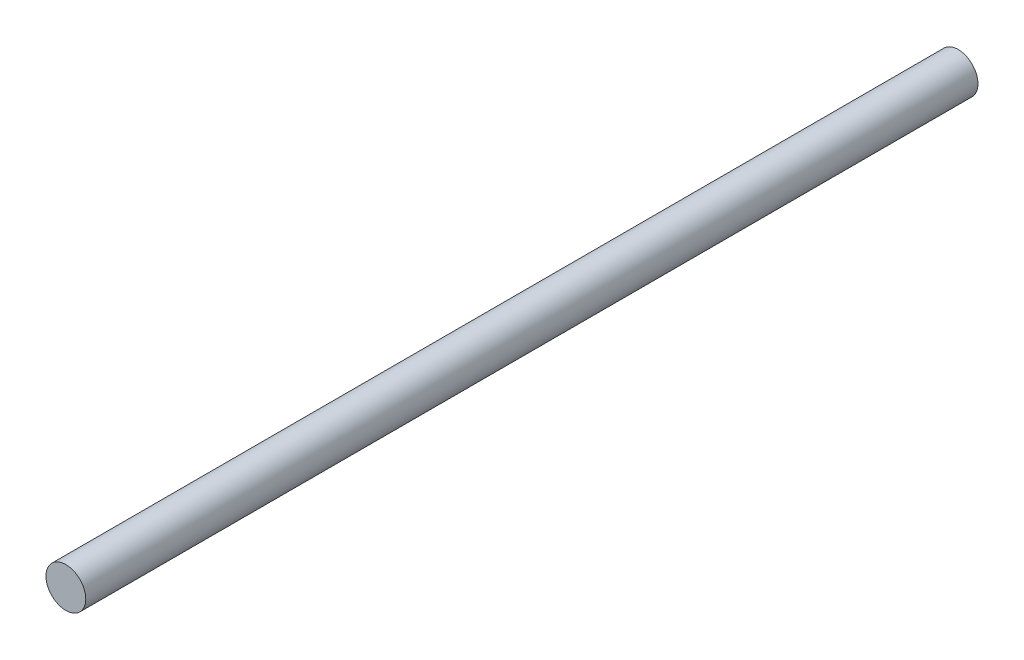
from build123d import *

# Parameters (mm, degrees)
SKETCH1_R           = 6
BOSS_EXTRUDE1_DEPTH = 269


with BuildPart() as part:
    # Sketch1 → Boss-Extrude1 (new body)
    with BuildSketch(Plane.XY):
        Circle(SKETCH1_R)
    extrude(amount=BOSS_EXTRUDE1_DEPTH)


solid = part.part
